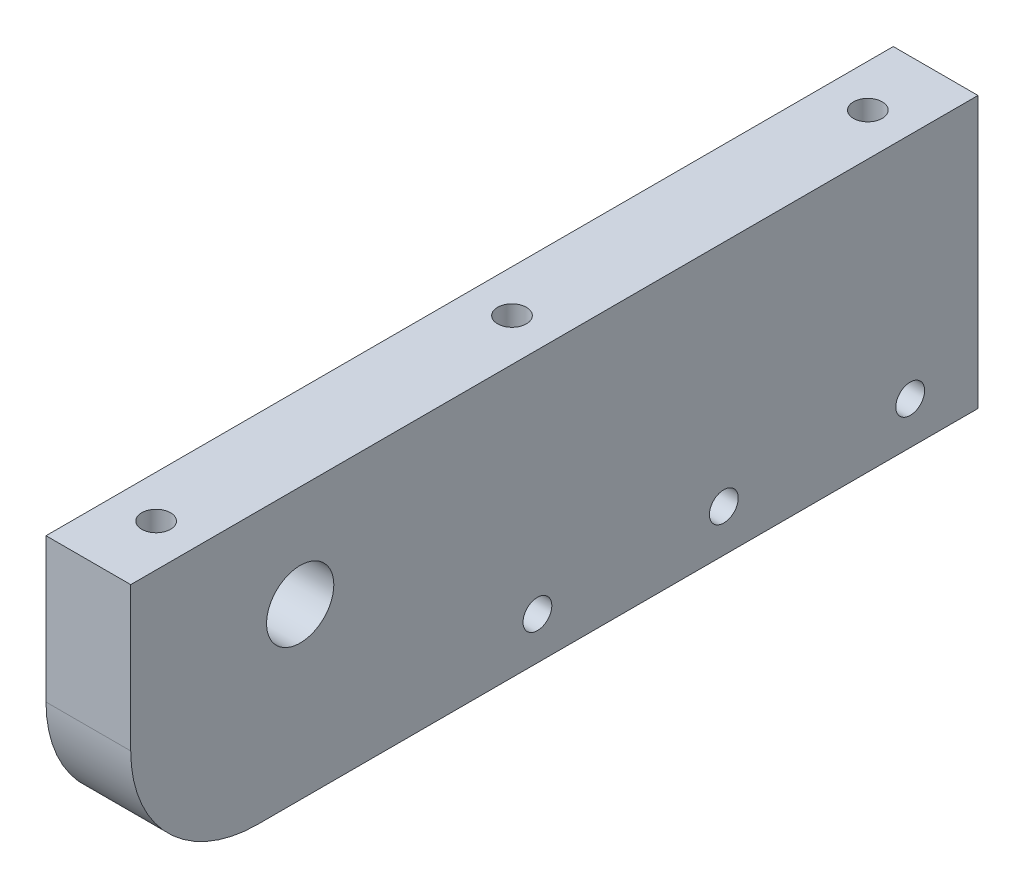
from build123d import *

# Parameters (mm, degrees)
SKETCH1_W                      = 100
SKETCH1_H                      = 32
SKETCH1_R                      = 3.96875
BOSS_EXTRUDE1_DEPTH            = 10
FILLET1_R                      = 15
CBORE_FOR_M3_SHCS_D            = 3.4
CBORE_FOR_M3_SHCS_DEPTH        = 23
CBORE_FOR_M3_SHCS_CBORE_D      = 6.5
CBORE_FOR_M3_SHCS_CBORE_DEPTH  = 3
CBORE_FOR_M3_SHCS_TIP          = 1.021463052
CBORE_FOR_M3_SHCS1_D           = 3.4
CBORE_FOR_M3_SHCS1_DEPTH       = 23
CBORE_FOR_M3_SHCS1_CBORE_D     = 6.5
CBORE_FOR_M3_SHCS1_CBORE_DEPTH = 3
CBORE_FOR_M3_SHCS1_TIP         = 1.021463052


with BuildPart() as part:
    # Sketch1 → Boss-Extrude1 (new body)
    with BuildSketch(Plane(origin=(0, 0, 0), x_dir=(0, 0, -1), z_dir=(1, 0, 0))):
        Rectangle(SKETCH1_W, SKETCH1_H)
        with Locations((-30, 4)):
            Circle(SKETCH1_R, mode=Mode.SUBTRACT)
    extrude(amount=BOSS_EXTRUDE1_DEPTH)

    # Fillet1
    fillet1_edges = [part.edges().sort_by_distance(p)[0] for p in [
        (5, -16, 50),
    ]]
    fillet(fillet1_edges, radius=FILLET1_R)

    # CBORE for M3 SHCS
    with Locations(Plane(origin=(-616.293536786, 26, -1323.282701689), x_dir=(1, 0, 0), z_dir=(0, 1, 0))):
        with Locations((731.293536786, -1281.282701689), (731.293536786, -1343.282701689), (621.293536786, -1281.282701689), (621.293536786, -1365.282701689), (621.293536786, -1323.282701689), (731.293536786, -1312.282701689)):
            CounterBoreHole(CBORE_FOR_M3_SHCS_D / 2, CBORE_FOR_M3_SHCS_CBORE_D / 2, CBORE_FOR_M3_SHCS_CBORE_DEPTH, depth=CBORE_FOR_M3_SHCS_DEPTH)
            with Locations((0, 0, -(CBORE_FOR_M3_SHCS_DEPTH + CBORE_FOR_M3_SHCS_TIP / 2))):  # 118° drill point
                Cone(0, CBORE_FOR_M3_SHCS_D / 2, CBORE_FOR_M3_SHCS_TIP, mode=Mode.SUBTRACT)

    # CBORE for M3 SHCS1
    with Locations(Plane(origin=(0, -904.012147263, -1323.282701689), x_dir=(0, 0, 1), z_dir=(-1, 0, 0))):
        with Locations((1281.282701689, 893.012147263), (1325.282701689, 893.012147263), (1303.282701689, 893.012147263)):
            CounterBoreHole(CBORE_FOR_M3_SHCS1_D / 2, CBORE_FOR_M3_SHCS1_CBORE_D / 2, CBORE_FOR_M3_SHCS1_CBORE_DEPTH, depth=CBORE_FOR_M3_SHCS1_DEPTH)
            with Locations((0, 0, -(CBORE_FOR_M3_SHCS1_DEPTH + CBORE_FOR_M3_SHCS1_TIP / 2))):  # 118° drill point
                Cone(0, CBORE_FOR_M3_SHCS1_D / 2, CBORE_FOR_M3_SHCS1_TIP, mode=Mode.SUBTRACT)


solid = part.part
